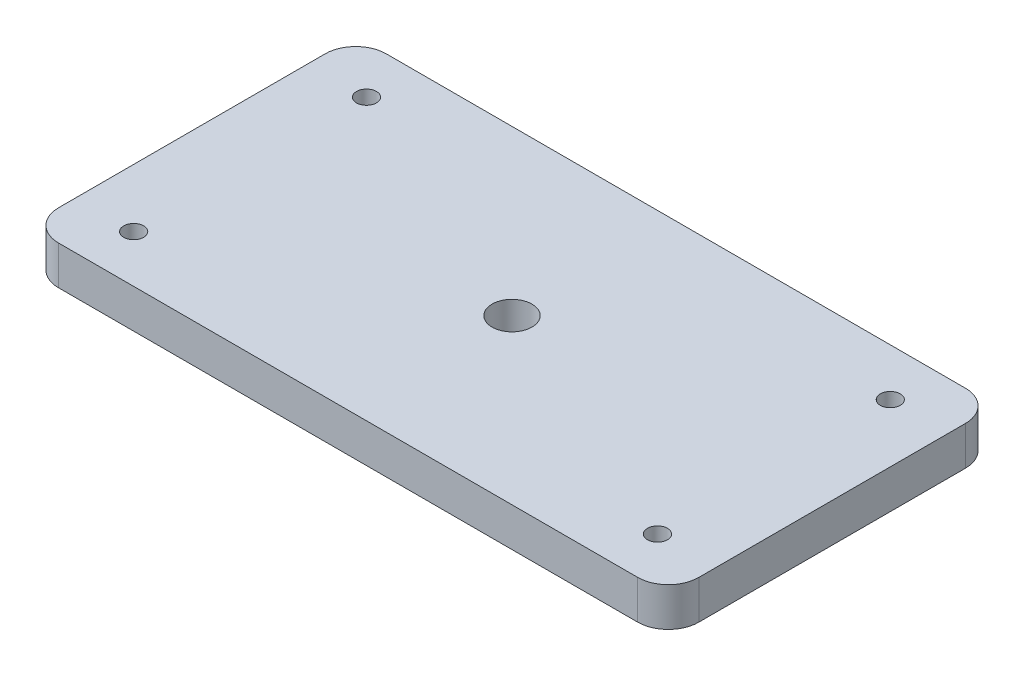
from build123d import *

# Parameters (mm, degrees)
SKETCH1_W                    = 104.78
SKETCH1_H                    = 53.63
BOSS_EXTRUDE1_DEPTH          = 6.35
F_0_257_DIAMETER_HOLE1_D     = 6.5278
F_30_0_1285_DIAMETER_HOLE1_D = 3.2639
FILLET1_R                    = 5


with BuildPart() as part:
    # Sketch1 → Boss-Extrude1 (new body)
    with BuildSketch(Plane(origin=(0, 0, 0), x_dir=(1, 0, 0), z_dir=(0, 1, 0))):
        with Locations((52.39, 26.815)):
            Rectangle(SKETCH1_W, SKETCH1_H)
    extrude(amount=BOSS_EXTRUDE1_DEPTH)

    # F (0.257) Diameter Hole1 (through all)
    with Locations(Plane(origin=(0, 0, 0), x_dir=(-1, 0, 0), z_dir=(0, -1, 0))):
        with Locations((-52.39, 26.815)):
            Hole(F_0_257_DIAMETER_HOLE1_D / 2)

    # #30 (0.1285) Diameter Hole1 (through all)
    with Locations(Plane(origin=(0, 0, 0), x_dir=(-1, 0, 0), z_dir=(0, -1, 0))):
        with Locations((-9.525, 7.765), (-9.525, 45.865), (-95.25, 45.865), (-95.25, 7.765)):
            Hole(F_30_0_1285_DIAMETER_HOLE1_D / 2)

    # Fillet1
    fillet1_edges = [part.edges().sort_by_distance(p)[0] for p in [
        (0, 3.175, -53.63),
        (104.78, 3.175, -53.63),
        (104.78, 3.175, 0),
        (0, 3.175, 0),
    ]]
    fillet(fillet1_edges, radius=FILLET1_R)


solid = part.part
